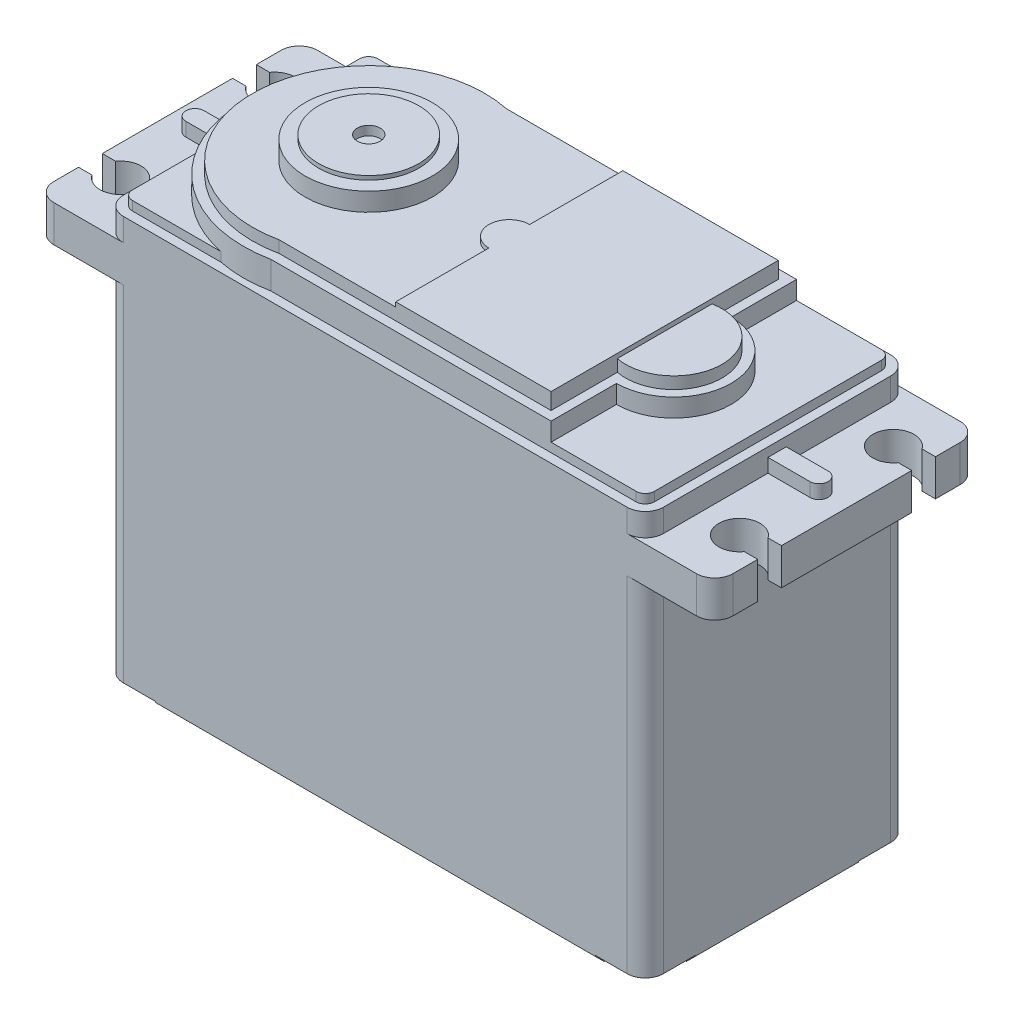
from build123d import *

# Parameters (mm, degrees)
CROQUIS1_W                      = 59.1
CROQUIS1_H                      = 28.85
SALIENTE_EXTRUIR1_DEPTH         = 22.65
CORTAR_EXTRUIR1_DEPTH           = 1.1
CHAFL_N1_SIZE                   = 1
REDONDEO1_R                     = 2
SALIENTE_EXTRUIR2_DEPTH         = 4
REDONDEO2_R                     = 2
SALIENTE_EXTRUIR3_DEPTH         = 1.5
SALIENTE_EXTRUIR4_DEPTH         = 1
SALIENTE_EXTRUIR5_DEPTH         = 3
SALIENTE_EXTRUIR6_DEPTH         = 1.3
CROQUIS8_R                      = 6.96
SALIENTE_EXTRUIR7_DEPTH         = 2
CROQUIS9_R                      = 5.485
SALIENTE_EXTRUIR8_DEPTH         = 0.44
CROQUIS10_R                     = 1.25
CORTAR_EXTRUIR2_DEPTH           = 1
TALADRO_DE_MARGEN_PARA_81_D     = 4.4958
TALADRO_DE_MARGEN_PARA_81_DEPTH = 4
SALIENTE_EXTRUIR9_DEPTH         = 0.5
CROQUIS17_W                     = 7.24
CROQUIS17_H                     = 4.41
CROQUIS18_W                     = 6.24
CROQUIS18_H                     = 3.41


with BuildPart() as part:
    # Croquis1 → Saliente-Extruir1 (new body, symmetric)
    with BuildSketch(Plane(origin=(0, 0, 0), x_dir=(1, 0, 0), z_dir=(0, 1, 0))):
        Rectangle(CROQUIS1_W, CROQUIS1_H)
    extrude(amount=SALIENTE_EXTRUIR1_DEPTH, both=True)

    # Croquis2 → Cortar-Extruir1 (cut)
    with BuildSketch(Plane.XZ.offset(22.65)):
        with BuildLine():
            Line((29.55, 14.425), (24.05, 14.425))
            Line((24.05, 14.425), (24.05, 10.925))
            ThreePointArc((24.05, 10.925), (24.635786438, 9.510786438), (26.05, 8.925))
            Line((26.05, 8.925), (29.55, 8.925))
            Line((29.55, 8.925), (29.55, 14.425))
        make_face()
        with BuildLine():
            Line((-29.55, 14.425), (-29.55, 8.925))
            Line((-29.55, 8.925), (-26.05, 8.925))
            ThreePointArc((-26.05, 8.925), (-24.635786438, 9.510786438), (-24.05, 10.925))
            Line((-24.05, 10.925), (-24.05, 14.425))
            Line((-24.05, 14.425), (-29.55, 14.425))
        make_face()
        with BuildLine():
            Line((24.05, -14.425), (24.05, -10.925))
            ThreePointArc((24.05, -10.925), (24.635786438, -9.510786438), (26.05, -8.925))
            Line((26.05, -8.925), (29.55, -8.925))
            Line((29.55, -8.925), (29.55, -14.425))
            Line((29.55, -14.425), (24.05, -14.425))
        make_face()
        with BuildLine():
            Line((-24.05, -14.425), (-24.05, -10.925))
            ThreePointArc((-24.05, -10.925), (-24.635786438, -9.510786438), (-26.05, -8.925))
            Line((-26.05, -8.925), (-29.55, -8.925))
            Line((-29.55, -8.925), (-29.55, -14.425))
            Line((-29.55, -14.425), (-24.05, -14.425))
        make_face()
    extrude(amount=-CORTAR_EXTRUIR1_DEPTH, mode=Mode.SUBTRACT)

    # Chafl_n1
    chafl_n1_edges = [part.edges().sort_by_distance(p)[0] for p in [
        (29.55, -22.65, 0),
        (0, -22.65, 14.425),
        (0, -22.65, -14.425),
        (-29.55, -22.65, 0),
    ]]
    chamfer(chafl_n1_edges, length=CHAFL_N1_SIZE)

    # Redondeo1
    redondeo1_edges = [part.edges().sort_by_distance(p)[0] for p in [
        (29.55, 0.55, 14.425),
        (-29.55, 0.55, 14.425),
        (-29.55, 0.55, -14.425),
        (29.55, 0.55, -14.425),
    ]]
    fillet(redondeo1_edges, radius=REDONDEO1_R)

    # Croquis3 → Saliente-Extruir2 (add)
    with BuildSketch(Plane(origin=(0, 16.15, 0), x_dir=(1, 0, 0), z_dir=(0, 1, 0))):
        with BuildLine():
            Line((27.55, 14.425), (37.15, 14.425))
            Line((37.15, 14.425), (37.15, 9.725))
            Line((37.15, 9.725), (35.599971428, 9.725))
            Line((35.599971428, 9.725), (35.599971428, 7.125))
            Line((35.599971428, 7.125), (37.15, 7.125))
            Line((37.15, 7.125), (37.15, -7.125))
            Line((37.15, -7.125), (35.599971428, -7.125))
            Line((35.599971428, -7.125), (35.599971428, -9.725))
            Line((35.599971428, -9.725), (37.15, -9.725))
            Line((37.15, -9.725), (37.15, -14.425))
            Line((37.15, -14.425), (27.55, -14.425))
            ThreePointArc((27.55, -14.425), (28.964213562, -13.839213562), (29.55, -12.425))
            Line((29.55, -12.425), (29.55, 12.425))
            ThreePointArc((29.55, 12.425), (28.964213562, 13.839213562), (27.55, 14.425))
        make_face()
        with BuildLine():
            Line((-37.15, -9.725), (-37.15, -14.425))
            Line((-37.15, -14.425), (-27.55, -14.425))
            ThreePointArc((-27.55, -14.425), (-28.964213562, -13.839213562), (-29.55, -12.425))
            Line((-29.55, -12.425), (-29.55, 12.425))
            ThreePointArc((-29.55, 12.425), (-28.964213562, 13.839213562), (-27.55, 14.425))
            Line((-27.55, 14.425), (-37.15, 14.425))
            Line((-37.15, 14.425), (-37.15, 9.725))
            Line((-37.15, 9.725), (-35.599971428, 9.725))
            Line((-35.599971428, 9.725), (-35.599971428, 7.125))
            Line((-35.599971428, 7.125), (-37.15, 7.125))
            Line((-37.15, 7.125), (-37.15, -7.125))
            Line((-37.15, -7.125), (-35.599971428, -7.125))
            Line((-35.599971428, -7.125), (-35.599971428, -9.725))
            Line((-35.599971428, -9.725), (-37.15, -9.725))
        make_face()
    extrude(amount=SALIENTE_EXTRUIR2_DEPTH)

    # Redondeo2
    redondeo2_edges = [part.edges().sort_by_distance(p)[0] for p in [
        (37.15, 18.15, 14.425),
        (37.15, 18.15, -14.425),
        (-37.15, 18.15, 14.425),
        (-37.15, 18.15, -14.425),
    ]]
    fillet(redondeo2_edges, radius=REDONDEO2_R)

    # Croquis4 → Saliente-Extruir3 (add)
    with BuildSketch(Plane(origin=(0, 20.15, 0), x_dir=(1, 0, 0), z_dir=(0, 1, 0))):
        with BuildLine():
            Line((34.13221447, -1), (29.55, -1))
            Line((29.55, -1), (29.55, 1))
            Line((29.55, 1), (34.13221447, 1))
            ThreePointArc((34.13221447, 1), (35.13221447, 0), (34.13221447, -1))
        make_face()
        with BuildLine():
            Line((-29.55, -1), (-29.55, 1))
            Line((-29.55, 1), (-34.13221447, 1))
            ThreePointArc((-34.13221447, 1), (-35.13221447, 0), (-34.13221447, -1))
            Line((-34.13221447, -1), (-29.55, -1))
        make_face()
    extrude(amount=SALIENTE_EXTRUIR3_DEPTH)

    # Croquis5 → Saliente-Extruir4 (add)
    with BuildSketch(Plane(origin=(0, 22.65, 0), x_dir=(1, 0, 0), z_dir=(0, 1, 0))):
        with BuildLine():
            Line((-27.55, -13.425), (27.55, -13.425))
            ThreePointArc((27.55, -13.425), (28.257106781, -13.132106781), (28.55, -12.425))
            Line((28.55, -12.425), (28.55, 12.425))
            ThreePointArc((28.55, 12.425), (28.257106781, 13.132106781), (27.55, 13.425))
            Line((27.55, 13.425), (-27.55, 13.425))
            ThreePointArc((-27.55, 13.425), (-28.257106781, 13.132106781), (-28.55, 12.425))
            Line((-28.55, 12.425), (-28.55, -12.425))
            ThreePointArc((-28.55, -12.425), (-28.257106781, -13.132106781), (-27.55, -13.425))
        make_face()
    extrude(amount=SALIENTE_EXTRUIR4_DEPTH)

    # Croquis6 → Saliente-Extruir5 (add)
    with BuildSketch(Plane(origin=(0, 22.65, 0), x_dir=(1, 0, 0), z_dir=(0, 1, 0))):
        with BuildLine():
            Line((-12.39381436, 13.425), (18.25, 13.425))
            Line((18.25, 13.425), (18.25, 6.275))
            ThreePointArc((18.25, 6.275), (24.525, 0), (18.25, -6.275))
            Line((18.25, -6.275), (18.25, -13.425))
            Line((18.25, -13.425), (-12.39381436, -13.425))
            ThreePointArc((-12.39381436, -13.425), (-28.825, 0), (-12.39381436, 13.425))
        make_face()
    extrude(amount=SALIENTE_EXTRUIR5_DEPTH)

    # Croquis7 → Saliente-Extruir6 (add)
    with BuildSketch(Plane(origin=(0, 25.65, 0), x_dir=(1, 0, 0), z_dir=(0, 1, 0))):
        with BuildLine():
            Line((17.25, 5.179346001), (17.25, 12.425))
            Line((17.25, 12.425), (-12.496430998, 12.425))
            ThreePointArc((-12.496430998, 12.425), (-27.825, 0), (-12.496430998, -12.425))
            Line((-12.496430998, -12.425), (17.25, -12.425))
            Line((17.25, -12.425), (17.25, -5.179346001))
            ThreePointArc((17.25, -5.179346001), (23.525, 0), (17.25, 5.179346001))
        make_face()
    extrude(amount=SALIENTE_EXTRUIR6_DEPTH)

    # Croquis8 → Saliente-Extruir7 (add)
    with BuildSketch(Plane(origin=(0, 26.95, 0), x_dir=(1, 0, 0), z_dir=(0, 1, 0))):
        with Locations((-15.125, 0)):
            Circle(CROQUIS8_R)
    extrude(amount=SALIENTE_EXTRUIR7_DEPTH)

    # Croquis9 → Saliente-Extruir8 (add)
    with BuildSketch(Plane(origin=(0, 28.95, 0), x_dir=(1, 0, 0), z_dir=(0, 1, 0))):
        with Locations((-15.125, 0)):
            Circle(CROQUIS9_R)
    extrude(amount=SALIENTE_EXTRUIR8_DEPTH)

    # Croquis10 → Cortar-Extruir2 (cut)
    with BuildSketch(Plane(origin=(0, 29.39, 0), x_dir=(1, 0, 0), z_dir=(0, 1, 0))):
        with Locations((-15.125, 0)):
            Circle(CROQUIS10_R)
    extrude(amount=-CORTAR_EXTRUIR2_DEPTH, mode=Mode.SUBTRACT)

    # Croquis11 → Taladro de margen para M1.61 (revolve, cut)
    with BuildSketch(Plane(origin=(27.05, -21.55, -11.925), x_dir=(0, 0, -1), z_dir=(1, 0, 0))):
        Polygon((0, 0), (0, 5.540774557), (0.9, 5), (0.9, 0), align=None)
    taladro_de_margen_para_m1_61 = revolve(axis=Axis((27.05, -27.9, -11.925), (0, 1, 0)), mode=Mode.SUBTRACT)

    # Simetr_a1: Taladro de margen para M1.61 across plane
    add(taladro_de_margen_para_m1_61.mirror(Plane.XY), mode=Mode.SUBTRACT)

    # Simetr_a2: Taladro de margen para M1.61 across plane
    add(taladro_de_margen_para_m1_61.mirror(Plane(origin=(0, 0, 0), x_dir=(0, 0, 1), z_dir=(1, 0, 0))), mode=Mode.SUBTRACT)

    # Simetr_a2 copy 1 sketch → Simetr_a2 copy 1 (revolve, cut)
    with BuildSketch(Plane(origin=(-27.05, -21.55, 11.925), x_dir=(0, 0, 1), z_dir=(-1, 0, 0))):
        Polygon((0, 0), (0, 5.540774557), (0.9, 5), (0.9, 0), align=None)
    revolve(axis=Axis((-27.05, -27.9, 11.925), (0, 1, 0)), mode=Mode.SUBTRACT)

    # Taladro de margen para _81
    with Locations(Plane(origin=(0, 20.15, 0), x_dir=(1, 0, 0), z_dir=(0, 1, 0))):
        with Locations((33.85, 8.425), (33.85, -8.425), (-33.85, 8.425), (-33.85, -8.425)):
            Hole(TALADRO_DE_MARGEN_PARA_81_D / 2, depth=TALADRO_DE_MARGEN_PARA_81_DEPTH)

    # Croquis15 → Saliente-Extruir9 (add)
    with BuildSketch(Plane(origin=(0, 26.95, 0), x_dir=(1, 0, 0), z_dir=(0, 1, 0))):
        with BuildLine():
            Line((17.25, 12.425), (0.25, 12.425))
            Line((0.25, 12.425), (0.25, 2.23))
            ThreePointArc((0.25, 2.23), (-1.98, 0), (0.25, -2.23))
            Line((0.25, -2.23), (0.25, -12.425))
            Line((0.25, -12.425), (17.25, -12.425))
            Line((17.25, -12.425), (17.25, 12.425))
        make_face()
    extrude(amount=SALIENTE_EXTRUIR9_DEPTH)

    # Croquis17 → Recubrir1 section 0
    with BuildSketch(Plane.ZY.offset(29.55)):
        with Locations((0, -16.595)):
            Rectangle(CROQUIS17_W, CROQUIS17_H)
    # Croquis18 → Recubrir1 section 1
    with BuildSketch(Plane.ZY.offset(35.55)):
        with Locations((0, -16.595)):
            Rectangle(CROQUIS18_W, CROQUIS18_H)
    loft()


solid = part.part
